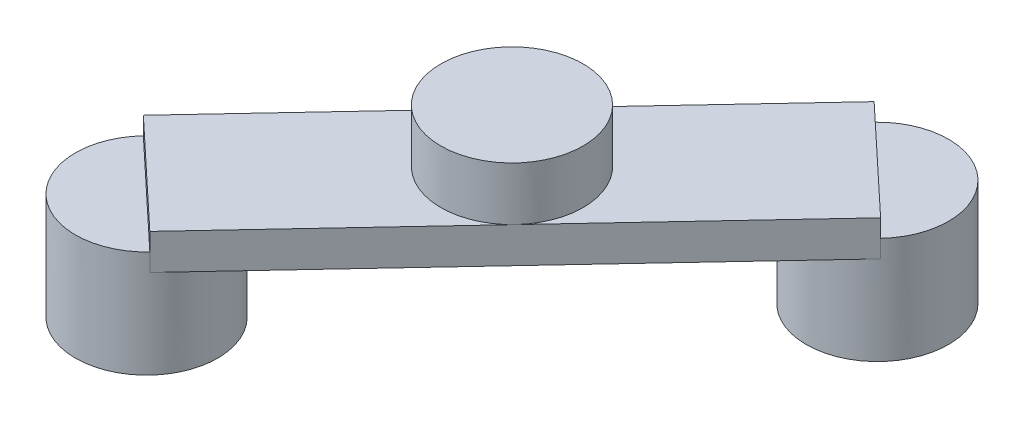
from build123d import *

# Parameters (mm, degrees)
SKETCH1_R             = 2
BOSS_EXTRUDE1_DEPTH   = 3
BOSS_EXTRUDE1_2_DEPTH = 3
BOSS_EXTRUDE2_DEPTH   = 4
SKETCH4_R             = 2
BOSS_EXTRUDE3_DEPTH   = 1.5


with BuildPart() as part:
    # Sketch1 → Boss-Extrude1 (new body)
    with BuildSketch(Plane(origin=(0, 0, 0), x_dir=(1, 0, 0), z_dir=(0, 1, 0))):
        with Locations((2.326314278, -12.139796801)):
            Circle(SKETCH1_R)
    extrude(amount=BOSS_EXTRUDE1_DEPTH)



with BuildPart() as body_2:
    # Sketch1 → Boss-Extrude1 2 (new body)
    with BuildSketch(Plane(origin=(0, 0, 0), x_dir=(1, 0, 0), z_dir=(0, 1, 0))):
        with Locations((12.264503501, -1.538947167)):
            Circle(SKETCH1_R)
    extrude(amount=BOSS_EXTRUDE1_2_DEPTH)


with BuildPart() as part_1:
    add(part.part)

    add(body_2.part)  # Boss-Extrude2 merges body 2
    # Sketch2 → Boss-Extrude2 (add)
    with BuildSketch(Plane(origin=(8.754490667, 0, 8.207246381), x_dir=(0.683937198, 0, -0.729540889), z_dir=(0.729540889, 0, 0.683937198))):
        Polygon((5.26542528, 3), (7.26542528, 3), (7.26542528, 3.5), (-7.26542528, 3.5), (-7.26542528, 3), align=None)
        Polygon((7.26542528, 2.5), (7.26542528, 3), (5.26542528, 3), (-7.26542528, 3), (-7.26542528, 2.5), align=None)
    extrude(amount=-BOSS_EXTRUDE2_DEPTH)

    # Sketch4 → Boss-Extrude3 (add)
    with BuildSketch(Plane(origin=(0, 3.5, 0), x_dir=(1, 0, 0), z_dir=(0, 1, 0))):
        with Locations((7.295408889, -6.839371984)):
            Circle(SKETCH4_R)
    extrude(amount=BOSS_EXTRUDE3_DEPTH)


solid = part_1.part
